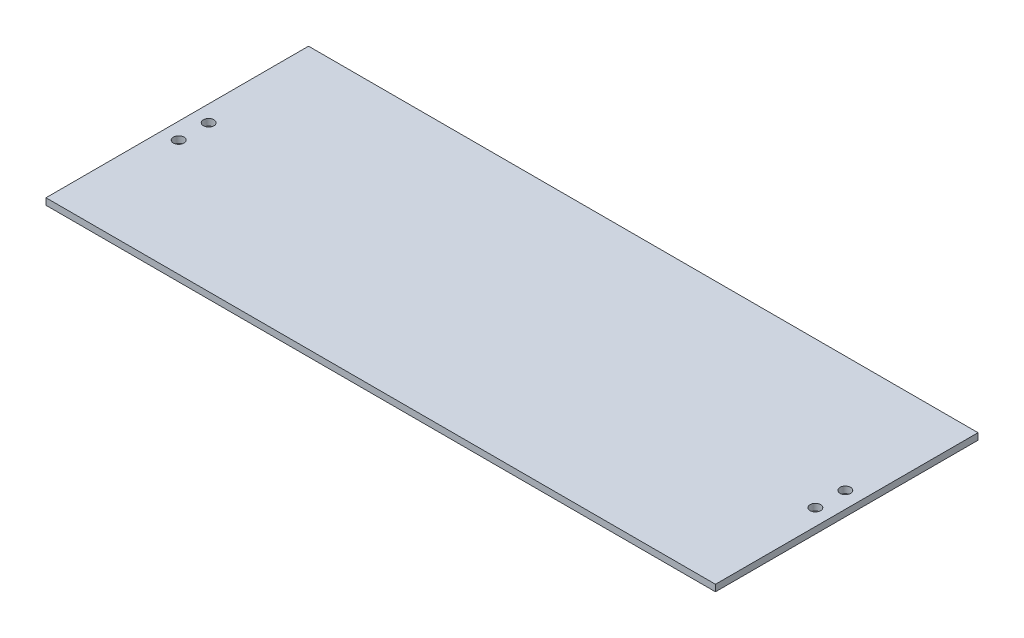
from build123d import *

# Parameters (mm, degrees)
SKETCH1_W                  = 323.85
SKETCH1_H                  = 127
BOSS_EXTRUDE1_DEPTH        = 3.175
F_10_CLEARANCE_HOLE1_D     = 5.1054
F_10_CLEARANCE_HOLE1_DEPTH = 12.7
F_10_CLEARANCE_HOLE1_TIP   = 1.533816902


with BuildPart() as part:
    # Sketch1 → Boss-Extrude1 (new body)
    with BuildSketch(Plane(origin=(0, 0, 0), x_dir=(1, 0, 0), z_dir=(0, 1, 0))):
        with Locations((161.925, 63.5)):
            Rectangle(SKETCH1_W, SKETCH1_H)
    extrude(amount=BOSS_EXTRUDE1_DEPTH)

    # #10 Clearance Hole1
    with Locations(Plane(origin=(0, 3.175, 0), x_dir=(1, 0, 0), z_dir=(0, 1, 0))):
        with Locations((315.9125, 70.75), (315.9125, 56.25), (7.9375, 70.75), (7.9375, 56.25)):
            Hole(F_10_CLEARANCE_HOLE1_D / 2, depth=F_10_CLEARANCE_HOLE1_DEPTH)
            with Locations((0, 0, -(F_10_CLEARANCE_HOLE1_DEPTH + F_10_CLEARANCE_HOLE1_TIP / 2))):  # 118° drill point
                Cone(0, F_10_CLEARANCE_HOLE1_D / 2, F_10_CLEARANCE_HOLE1_TIP, mode=Mode.SUBTRACT)


solid = part.part
